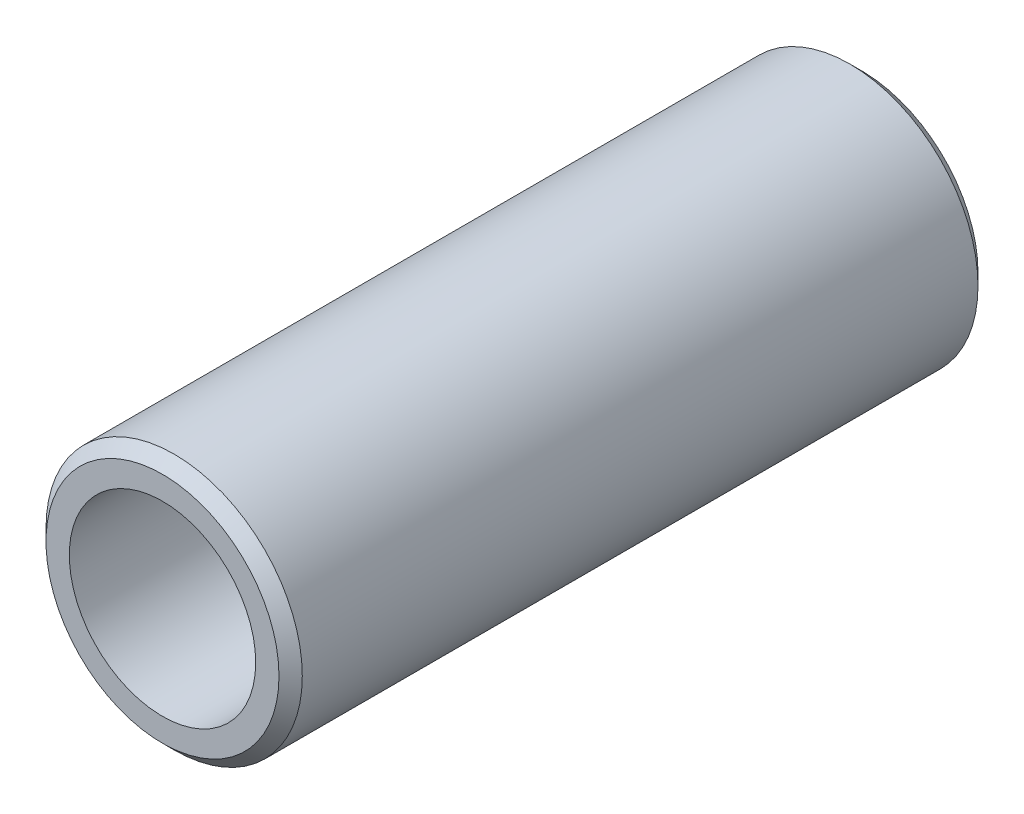
from build123d import *

# Parameters (mm, degrees)
SCHIZZO1_R                   = 5.5
ESTRUSIONE_ESTRUSIONE1_DEPTH = 30
SCHIZZO2_R                   = 4
TAGLIO_ESTRUSIONE1_DEPTH     = 31
SMUSSO1_SIZE                 = 0.5


with BuildPart() as part:
    # Schizzo1 → Estrusione-Estrusione1 (new body)
    with BuildSketch(Plane.XY):
        Circle(SCHIZZO1_R)
    extrude(amount=ESTRUSIONE_ESTRUSIONE1_DEPTH)

    # Schizzo2 → Taglio-Estrusione1 (cut, through all)
    with BuildSketch(Plane.XY.offset(30)):
        Circle(SCHIZZO2_R)
    extrude(amount=-TAGLIO_ESTRUSIONE1_DEPTH, mode=Mode.SUBTRACT)

    # Smusso1
    smusso1_edges = [part.edges().sort_by_distance(p)[0] for p in [
        (-5.5, 0, 0),
        (-5.5, 0, 30),
    ]]
    chamfer(smusso1_edges, length=SMUSSO1_SIZE)


solid = part.part
